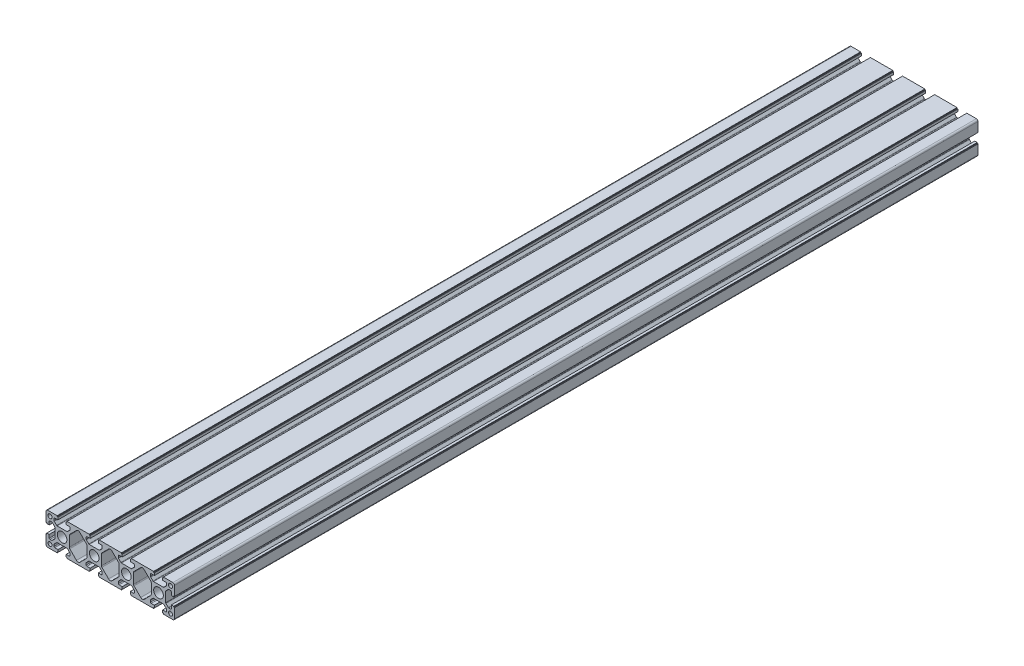
from build123d import *

# Parameters (mm, degrees)
SKETCH_1_R      = 2.5
SKETCH_1_R_2    = 6
EXTRUDE_1_DEPTH = 1000


with BuildPart() as part:
    # 草图1 → 拉伸1 (new body)
    with BuildSketch(Plane.XY):
        with BuildLine():
            Line((67.752237322, 25.298883207), (67.752237322, 26.298883207))
            Line((67.752237322, 26.298883207), (66.752237322, 26.298883207))
            Line((66.752237322, 26.298883207), (66.752237322, 29.298883207))
            Line((66.752237322, 29.298883207), (70.652237322, 29.298883207))
            ThreePointArc((70.652237322, 29.298883207), (71.359344103, 29.591776426), (71.652237322, 30.298883207))
            Line((71.652237322, 30.298883207), (71.652237322, 32.409795911))
            ThreePointArc((71.652237322, 32.409795911), (71.576116855, 32.792479343), (71.359344103, 33.116902692))
            Line((71.359344103, 33.116902692), (68.470256807, 36.005989988))
            ThreePointArc((68.470256807, 36.005989988), (68.145833458, 36.22276274), (67.763150026, 36.298883207))
            Line((67.763150026, 36.298883207), (55.541324619, 36.298883207))
            ThreePointArc((55.541324619, 36.298883207), (55.158641186, 36.22276274), (54.834217838, 36.005989988))
            Line((54.834217838, 36.005989988), (51.945130541, 33.116902692))
            ThreePointArc((51.945130541, 33.116902692), (51.72835779, 32.792479343), (51.652237322, 32.409795911))
            Line((51.652237322, 32.409795911), (51.652237322, 30.298883207))
            ThreePointArc((51.652237322, 30.298883207), (51.945130541, 29.591776426), (52.652237322, 29.298883207))
            Line((52.652237322, 29.298883207), (56.552237322, 29.298883207))
            Line((56.552237322, 29.298883207), (56.552237322, 26.298883207))
            Line((56.552237322, 26.298883207), (55.552237322, 26.298883207))
            Line((55.552237322, 26.298883207), (55.552237322, 25.298883207))
            Line((55.552237322, 25.298883207), (27.752237322, 25.298883207))
            Line((27.752237322, 25.298883207), (27.752237322, 26.298883207))
            Line((27.752237322, 26.298883207), (26.752237322, 26.298883207))
            Line((26.752237322, 26.298883207), (26.752237322, 29.298883207))
            Line((26.752237322, 29.298883207), (30.652237322, 29.298883207))
            ThreePointArc((30.652237322, 29.298883207), (31.359344103, 29.591776426), (31.652237322, 30.298883207))
            Line((31.652237322, 30.298883207), (31.652237322, 32.409795911))
            ThreePointArc((31.652237322, 32.409795911), (31.576116855, 32.792479343), (31.359344103, 33.116902692))
            Line((31.359344103, 33.116902692), (28.470256807, 36.005989988))
            ThreePointArc((28.470256807, 36.005989988), (28.145833458, 36.22276274), (27.763150026, 36.298883207))
            Line((27.763150026, 36.298883207), (15.541324619, 36.298883207))
            ThreePointArc((15.541324619, 36.298883207), (15.158641186, 36.22276274), (14.834217838, 36.005989988))
            Line((14.834217838, 36.005989988), (11.945130541, 33.116902692))
            ThreePointArc((11.945130541, 33.116902692), (11.72835779, 32.792479343), (11.652237322, 32.409795911))
            Line((11.652237322, 32.409795911), (11.652237322, 30.298883207))
            ThreePointArc((11.652237322, 30.298883207), (11.945130541, 29.591776426), (12.652237322, 29.298883207))
            Line((12.652237322, 29.298883207), (16.552237322, 29.298883207))
            Line((16.552237322, 29.298883207), (16.552237322, 26.298883207))
            Line((16.552237322, 26.298883207), (15.552237322, 26.298883207))
            Line((15.552237322, 26.298883207), (15.552237322, 25.298883207))
            Line((15.552237322, 25.298883207), (3.652237322, 25.298883207))
            ThreePointArc((3.652237322, 25.298883207), (2.23802376, 25.884669645), (1.652237322, 27.298883207))
            Line((1.652237322, 27.298883207), (1.652237322, 39.198883207))
            Line((1.652237322, 39.198883207), (2.652237322, 39.198883207))
            Line((2.652237322, 39.198883207), (2.652237322, 40.198883207))
            Line((2.652237322, 40.198883207), (5.652237322, 40.198883207))
            Line((5.652237322, 40.198883207), (5.652237322, 36.298883207))
            ThreePointArc((5.652237322, 36.298883207), (5.945130541, 35.591776426), (6.652237322, 35.298883207))
            Line((6.652237322, 35.298883207), (8.763150026, 35.298883207))
            ThreePointArc((8.763150026, 35.298883207), (9.145833458, 35.375003675), (9.470256807, 35.591776426))
            Line((9.470256807, 35.591776426), (12.359344103, 38.480863722))
            ThreePointArc((12.359344103, 38.480863722), (12.576116855, 38.805287071), (12.652237322, 39.187970504))
            Line((12.652237322, 39.187970504), (12.652237322, 51.409795911))
            ThreePointArc((12.652237322, 51.409795911), (12.576116855, 51.792479343), (12.359344103, 52.116902692))
            Line((12.359344103, 52.116902692), (9.470256807, 55.005989988))
            ThreePointArc((9.470256807, 55.005989988), (9.145833458, 55.22276274), (8.763150026, 55.298883207))
            Line((8.763150026, 55.298883207), (6.652237322, 55.298883207))
            ThreePointArc((6.652237322, 55.298883207), (5.945130541, 55.005989988), (5.652237322, 54.298883207))
            Line((5.652237322, 54.298883207), (5.652237322, 50.398883207))
            Line((5.652237322, 50.398883207), (2.652237322, 50.398883207))
            Line((2.652237322, 50.398883207), (2.652237322, 51.398883207))
            Line((2.652237322, 51.398883207), (1.652237322, 51.398883207))
            Line((1.652237322, 51.398883207), (1.652237322, 63.298883207))
            ThreePointArc((1.652237322, 63.298883207), (2.23802376, 64.713096769), (3.652237322, 65.298883207))
            Line((3.652237322, 65.298883207), (15.552237322, 65.298883207))
            Line((15.552237322, 65.298883207), (15.552237322, 64.298883207))
            Line((15.552237322, 64.298883207), (16.552237322, 64.298883207))
            Line((16.552237322, 64.298883207), (16.552237322, 61.298883207))
            Line((16.552237322, 61.298883207), (12.652237322, 61.298883207))
            ThreePointArc((12.652237322, 61.298883207), (11.945130541, 61.005989988), (11.652237322, 60.298883207))
            Line((11.652237322, 60.298883207), (11.652237322, 58.187970504))
            ThreePointArc((11.652237322, 58.187970504), (11.72835779, 57.805287071), (11.945130541, 57.480863722))
            Line((11.945130541, 57.480863722), (14.834217838, 54.591776426))
            ThreePointArc((14.834217838, 54.591776426), (15.158641186, 54.375003675), (15.541324619, 54.298883207))
            Line((15.541324619, 54.298883207), (27.763150026, 54.298883207))
            ThreePointArc((27.763150026, 54.298883207), (28.145833458, 54.375003675), (28.470256807, 54.591776426))
            Line((28.470256807, 54.591776426), (31.359344103, 57.480863722))
            ThreePointArc((31.359344103, 57.480863722), (31.576116855, 57.805287071), (31.652237322, 58.187970504))
            Line((31.652237322, 58.187970504), (31.652237322, 60.298883207))
            ThreePointArc((31.652237322, 60.298883207), (31.359344103, 61.005989988), (30.652237322, 61.298883207))
            Line((30.652237322, 61.298883207), (26.752237322, 61.298883207))
            Line((26.752237322, 61.298883207), (26.752237322, 64.298883207))
            Line((26.752237322, 64.298883207), (27.752237322, 64.298883207))
            Line((27.752237322, 64.298883207), (27.752237322, 65.298883207))
            Line((27.752237322, 65.298883207), (55.552237322, 65.298883207))
            Line((55.552237322, 65.298883207), (55.552237322, 64.298883207))
            Line((55.552237322, 64.298883207), (56.552237322, 64.298883207))
            Line((56.552237322, 64.298883207), (56.552237322, 61.298883207))
            Line((56.552237322, 61.298883207), (52.652237322, 61.298883207))
            ThreePointArc((52.652237322, 61.298883207), (51.945130541, 61.005989988), (51.652237322, 60.298883207))
            Line((51.652237322, 60.298883207), (51.652237322, 58.187970504))
            ThreePointArc((51.652237322, 58.187970504), (51.72835779, 57.805287071), (51.945130541, 57.480863722))
            Line((51.945130541, 57.480863722), (54.834217838, 54.591776426))
            ThreePointArc((54.834217838, 54.591776426), (55.158641186, 54.375003675), (55.541324619, 54.298883207))
            Line((55.541324619, 54.298883207), (67.763150026, 54.298883207))
            ThreePointArc((67.763150026, 54.298883207), (68.145833458, 54.375003675), (68.470256807, 54.591776426))
            Line((68.470256807, 54.591776426), (71.359344103, 57.480863722))
            ThreePointArc((71.359344103, 57.480863722), (71.576116855, 57.805287071), (71.652237322, 58.187970504))
            Line((71.652237322, 58.187970504), (71.652237322, 60.298883207))
            ThreePointArc((71.652237322, 60.298883207), (71.359344103, 61.005989988), (70.652237322, 61.298883207))
            Line((70.652237322, 61.298883207), (66.752237322, 61.298883207))
            Line((66.752237322, 61.298883207), (66.752237322, 64.298883207))
            Line((66.752237322, 64.298883207), (67.752237322, 64.298883207))
            Line((67.752237322, 64.298883207), (67.752237322, 65.298883207))
            Line((67.752237322, 65.298883207), (95.552237322, 65.298883207))
            Line((95.552237322, 65.298883207), (95.552237322, 64.298883207))
            Line((95.552237322, 64.298883207), (96.552237322, 64.298883207))
            Line((96.552237322, 64.298883207), (96.552237322, 61.298883207))
            Line((96.552237322, 61.298883207), (92.652237322, 61.298883207))
            ThreePointArc((92.652237322, 61.298883207), (91.945130541, 61.005989988), (91.652237322, 60.298883207))
            Line((91.652237322, 60.298883207), (91.652237322, 58.187970504))
            ThreePointArc((91.652237322, 58.187970504), (91.72835779, 57.805287071), (91.945130541, 57.480863722))
            Line((91.945130541, 57.480863722), (94.834217838, 54.591776426))
            ThreePointArc((94.834217838, 54.591776426), (95.158641186, 54.375003675), (95.541324619, 54.298883207))
            Line((95.541324619, 54.298883207), (107.763150026, 54.298883207))
            ThreePointArc((107.763150026, 54.298883207), (108.145833458, 54.375003675), (108.470256807, 54.591776426))
            Line((108.470256807, 54.591776426), (111.359344103, 57.480863722))
            ThreePointArc((111.359344103, 57.480863722), (111.576116855, 57.805287071), (111.652237322, 58.187970504))
            Line((111.652237322, 58.187970504), (111.652237322, 60.298883207))
            ThreePointArc((111.652237322, 60.298883207), (111.359344103, 61.005989988), (110.652237322, 61.298883207))
            Line((110.652237322, 61.298883207), (106.752237322, 61.298883207))
            Line((106.752237322, 61.298883207), (106.752237322, 64.298883207))
            Line((106.752237322, 64.298883207), (107.752237322, 64.298883207))
            Line((107.752237322, 64.298883207), (107.752237322, 65.298883207))
            Line((107.752237322, 65.298883207), (135.552237322, 65.298883207))
            Line((135.552237322, 65.298883207), (135.552237322, 64.298883207))
            Line((135.552237322, 64.298883207), (136.552237322, 64.298883207))
            Line((136.552237322, 64.298883207), (136.552237322, 61.298883207))
            Line((136.552237322, 61.298883207), (132.652237322, 61.298883207))
            ThreePointArc((132.652237322, 61.298883207), (131.945130541, 61.005989988), (131.652237322, 60.298883207))
            Line((131.652237322, 60.298883207), (131.652237322, 58.187970504))
            ThreePointArc((131.652237322, 58.187970504), (131.72835779, 57.805287071), (131.945130541, 57.480863722))
            Line((131.945130541, 57.480863722), (134.834217838, 54.591776426))
            ThreePointArc((134.834217838, 54.591776426), (135.158641186, 54.375003675), (135.541324619, 54.298883207))
            Line((135.541324619, 54.298883207), (147.763150026, 54.298883207))
            ThreePointArc((147.763150026, 54.298883207), (148.145833458, 54.375003675), (148.470256807, 54.591776426))
            Line((148.470256807, 54.591776426), (151.359344103, 57.480863722))
            ThreePointArc((151.359344103, 57.480863722), (151.576116855, 57.805287071), (151.652237322, 58.187970504))
            Line((151.652237322, 58.187970504), (151.652237322, 60.298883207))
            ThreePointArc((151.652237322, 60.298883207), (151.359344103, 61.005989988), (150.652237322, 61.298883207))
            Line((150.652237322, 61.298883207), (146.752237322, 61.298883207))
            Line((146.752237322, 61.298883207), (146.752237322, 64.298883207))
            Line((146.752237322, 64.298883207), (147.752237322, 64.298883207))
            Line((147.752237322, 64.298883207), (147.752237322, 65.298883207))
            Line((147.752237322, 65.298883207), (159.652237322, 65.298883207))
            ThreePointArc((159.652237322, 65.298883207), (161.066450885, 64.713096769), (161.652237322, 63.298883207))
            Line((161.652237322, 63.298883207), (161.652237322, 51.398883207))
            Line((161.652237322, 51.398883207), (160.652237322, 51.398883207))
            Line((160.652237322, 51.398883207), (160.652237322, 50.398883207))
            Line((160.652237322, 50.398883207), (157.652237322, 50.398883207))
            Line((157.652237322, 50.398883207), (157.652237322, 54.298883207))
            ThreePointArc((157.652237322, 54.298883207), (157.359344103, 55.005989988), (156.652237322, 55.298883207))
            Line((156.652237322, 55.298883207), (154.541324619, 55.298883207))
            ThreePointArc((154.541324619, 55.298883207), (154.158641186, 55.22276274), (153.834217838, 55.005989988))
            Line((153.834217838, 55.005989988), (150.945130541, 52.116902692))
            ThreePointArc((150.945130541, 52.116902692), (150.72835779, 51.792479343), (150.652237322, 51.409795911))
            Line((150.652237322, 51.409795911), (150.652237322, 39.187970504))
            ThreePointArc((150.652237322, 39.187970504), (150.72835779, 38.805287071), (150.945130541, 38.480863722))
            Line((150.945130541, 38.480863722), (153.834217838, 35.591776426))
            ThreePointArc((153.834217838, 35.591776426), (154.158641186, 35.375003675), (154.541324619, 35.298883207))
            Line((154.541324619, 35.298883207), (156.652237322, 35.298883207))
            ThreePointArc((156.652237322, 35.298883207), (157.359344103, 35.591776426), (157.652237322, 36.298883207))
            Line((157.652237322, 36.298883207), (157.652237322, 40.198883207))
            Line((157.652237322, 40.198883207), (160.652237322, 40.198883207))
            Line((160.652237322, 40.198883207), (160.652237322, 39.198883207))
            Line((160.652237322, 39.198883207), (161.652237322, 39.198883207))
            Line((161.652237322, 39.198883207), (161.652237322, 27.298883207))
            ThreePointArc((161.652237322, 27.298883207), (161.066450885, 25.884669645), (159.652237322, 25.298883207))
            Line((159.652237322, 25.298883207), (147.752237322, 25.298883207))
            Line((147.752237322, 25.298883207), (147.752237322, 26.298883207))
            Line((147.752237322, 26.298883207), (146.752237322, 26.298883207))
            Line((146.752237322, 26.298883207), (146.752237322, 29.298883207))
            Line((146.752237322, 29.298883207), (150.652237322, 29.298883207))
            ThreePointArc((150.652237322, 29.298883207), (151.359344103, 29.591776426), (151.652237322, 30.298883207))
            Line((151.652237322, 30.298883207), (151.652237322, 32.409795911))
            ThreePointArc((151.652237322, 32.409795911), (151.576116855, 32.792479343), (151.359344103, 33.116902692))
            Line((151.359344103, 33.116902692), (148.470256807, 36.005989988))
            ThreePointArc((148.470256807, 36.005989988), (148.145833458, 36.22276274), (147.763150026, 36.298883207))
            Line((147.763150026, 36.298883207), (135.541324619, 36.298883207))
            ThreePointArc((135.541324619, 36.298883207), (135.158641186, 36.22276274), (134.834217838, 36.005989988))
            Line((134.834217838, 36.005989988), (131.945130541, 33.116902692))
            ThreePointArc((131.945130541, 33.116902692), (131.72835779, 32.792479343), (131.652237322, 32.409795911))
            Line((131.652237322, 32.409795911), (131.652237322, 30.298883207))
            ThreePointArc((131.652237322, 30.298883207), (131.945130541, 29.591776426), (132.652237322, 29.298883207))
            Line((132.652237322, 29.298883207), (136.552237322, 29.298883207))
            Line((136.552237322, 29.298883207), (136.552237322, 26.298883207))
            Line((136.552237322, 26.298883207), (135.552237322, 26.298883207))
            Line((135.552237322, 26.298883207), (135.552237322, 25.298883207))
            Line((135.552237322, 25.298883207), (107.752237322, 25.298883207))
            Line((107.752237322, 25.298883207), (107.752237322, 26.298883207))
            Line((107.752237322, 26.298883207), (106.752237322, 26.298883207))
            Line((106.752237322, 26.298883207), (106.752237322, 29.298883207))
            Line((106.752237322, 29.298883207), (110.652237322, 29.298883207))
            ThreePointArc((110.652237322, 29.298883207), (111.359344103, 29.591776426), (111.652237322, 30.298883207))
            Line((111.652237322, 30.298883207), (111.652237322, 32.409795911))
            ThreePointArc((111.652237322, 32.409795911), (111.576116855, 32.792479343), (111.359344103, 33.116902692))
            Line((111.359344103, 33.116902692), (108.470256807, 36.005989988))
            ThreePointArc((108.470256807, 36.005989988), (108.145833458, 36.22276274), (107.763150026, 36.298883207))
            Line((107.763150026, 36.298883207), (95.541324619, 36.298883207))
            ThreePointArc((95.541324619, 36.298883207), (95.158641186, 36.22276274), (94.834217838, 36.005989988))
            Line((94.834217838, 36.005989988), (91.945130541, 33.116902692))
            ThreePointArc((91.945130541, 33.116902692), (91.72835779, 32.792479343), (91.652237322, 32.409795911))
            Line((91.652237322, 32.409795911), (91.652237322, 30.298883207))
            ThreePointArc((91.652237322, 30.298883207), (91.945130541, 29.591776426), (92.652237322, 29.298883207))
            Line((92.652237322, 29.298883207), (96.552237322, 29.298883207))
            Line((96.552237322, 29.298883207), (96.552237322, 26.298883207))
            Line((96.552237322, 26.298883207), (95.552237322, 26.298883207))
            Line((95.552237322, 26.298883207), (95.552237322, 25.298883207))
            Line((95.552237322, 25.298883207), (67.752237322, 25.298883207))
        make_face()
        with Locations((6.652237322, 60.298883207)):
            Circle(SKETCH_1_R, mode=Mode.SUBTRACT)
        with Locations((6.652237322, 30.298883207)):
            Circle(SKETCH_1_R, mode=Mode.SUBTRACT)
        with Locations((21.652237322, 45.298883207)):
            Circle(SKETCH_1_R_2, mode=Mode.SUBTRACT)
        with Locations((61.652237322, 45.298883207)):
            Circle(SKETCH_1_R_2, mode=Mode.SUBTRACT)
        with Locations((101.652237322, 45.298883207)):
            Circle(SKETCH_1_R_2, mode=Mode.SUBTRACT)
        with Locations((141.652237322, 45.298883207)):
            Circle(SKETCH_1_R_2, mode=Mode.SUBTRACT)
        with Locations((156.652237322, 30.298883207)):
            Circle(SKETCH_1_R, mode=Mode.SUBTRACT)
        with Locations((156.652237322, 60.298883207)):
            Circle(SKETCH_1_R, mode=Mode.SUBTRACT)
        with BuildLine():
            Line((52.066450885, 53.116902692), (43.773557666, 61.409795911))
            ThreePointArc((43.773557666, 61.409795911), (41.652237322, 62.288475567), (39.530916979, 61.409795911))
            Line((39.530916979, 61.409795911), (31.23802376, 53.116902692))
            ThreePointArc((31.23802376, 53.116902692), (30.804478257, 52.468055994), (30.652237322, 51.702689129))
            Line((30.652237322, 51.702689129), (30.652237322, 38.895077285))
            ThreePointArc((30.652237322, 38.895077285), (30.804478257, 38.12971042), (31.23802376, 37.480863722))
            Line((31.23802376, 37.480863722), (39.530916965, 29.187970518))
            ThreePointArc((39.530916965, 29.187970518), (41.652237308, 28.309290861), (43.773557652, 29.187970518))
            Line((43.773557652, 29.187970518), (52.066450885, 37.480863751))
            ThreePointArc((52.066450885, 37.480863751), (52.499996387, 38.129710448), (52.652237322, 38.895077313))
            Line((52.652237322, 38.895077313), (52.652237322, 51.702689129))
            ThreePointArc((52.652237322, 51.702689129), (52.499996387, 52.468055994), (52.066450885, 53.116902692))
        make_face(mode=Mode.SUBTRACT)
        with BuildLine():
            Line((123.77355768, 29.18797049), (132.066450885, 37.480863694))
            ThreePointArc((132.066450885, 37.480863694), (132.499996387, 38.129710392), (132.652237322, 38.895077257))
            Line((132.652237322, 38.895077257), (132.652237322, 51.702689129))
            ThreePointArc((132.652237322, 51.702689129), (132.499996387, 52.468055994), (132.066450885, 53.116902692))
            Line((132.066450885, 53.116902692), (123.773557666, 61.409795911))
            ThreePointArc((123.773557666, 61.409795911), (121.652237322, 62.288475567), (119.530916979, 61.409795911))
            Line((119.530916979, 61.409795911), (111.23802376, 53.116902692))
            ThreePointArc((111.23802376, 53.116902692), (110.804478257, 52.468055994), (110.652237322, 51.702689129))
            Line((110.652237322, 51.702689129), (110.652237322, 38.895077285))
            ThreePointArc((110.652237322, 38.895077285), (110.804478257, 38.12971042), (111.23802376, 37.480863722))
            Line((111.23802376, 37.480863722), (119.530916993, 29.18797049))
            ThreePointArc((119.530916993, 29.18797049), (121.652237336, 28.309290833), (123.77355768, 29.18797049))
        make_face(mode=Mode.SUBTRACT)
        with BuildLine():
            Line((83.77355768, 29.18797049), (92.066450885, 37.480863694))
            ThreePointArc((92.066450885, 37.480863694), (92.499996387, 38.129710392), (92.652237322, 38.895077257))
            Line((92.652237322, 38.895077257), (92.652237322, 51.702689129))
            ThreePointArc((92.652237322, 51.702689129), (92.499996387, 52.468055994), (92.066450885, 53.116902692))
            Line((92.066450885, 53.116902692), (83.773557666, 61.409795911))
            ThreePointArc((83.773557666, 61.409795911), (81.652237322, 62.288475567), (79.530916979, 61.409795911))
            Line((79.530916979, 61.409795911), (71.23802376, 53.116902692))
            ThreePointArc((71.23802376, 53.116902692), (70.804478257, 52.468055994), (70.652237322, 51.702689129))
            Line((70.652237322, 51.702689129), (70.652237322, 38.895077285))
            ThreePointArc((70.652237322, 38.895077285), (70.804478257, 38.12971042), (71.23802376, 37.480863722))
            Line((71.23802376, 37.480863722), (79.530916993, 29.18797049))
            ThreePointArc((79.530916993, 29.18797049), (81.652237336, 28.309290833), (83.77355768, 29.18797049))
        make_face(mode=Mode.SUBTRACT)
    extrude(amount=EXTRUDE_1_DEPTH)


solid = part.part
